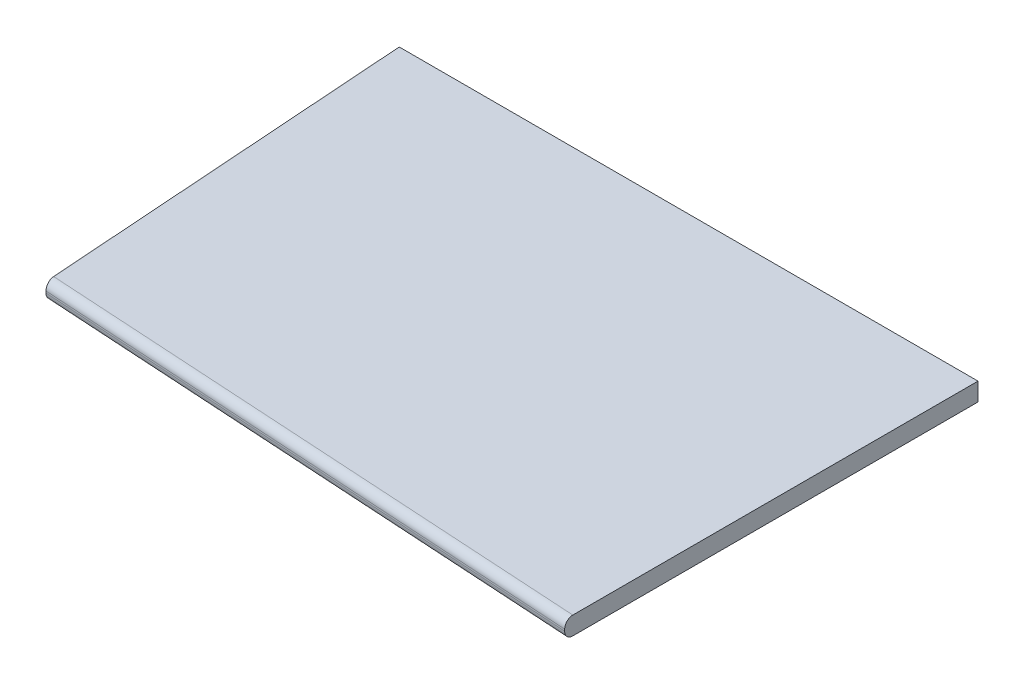
from build123d import *

# Parameters (mm, degrees)
BOSS_EXTRUDE1_DEPTH = 1.27
FILLET1_R           = 1.143


with BuildPart() as part:
    # Sketch1 → Boss-Extrude1 (new body, symmetric)
    with BuildSketch(Plane(origin=(0, 0, 0), x_dir=(1, 0, 0), z_dir=(0, 1, 0))):
        Polygon((0, 0), (81.28, 0), (81.28, -58.049008178), (3.729896149, -53.34), align=None)
    extrude(amount=BOSS_EXTRUDE1_DEPTH, both=True)

    # Fillet1
    fillet1_edges = [part.edges().sort_by_distance(p)[0] for p in [
        (42.504948075, -1.27, 55.694504089),
        (42.504948075, 1.27, 55.694504089),
    ]]
    fillet(fillet1_edges, radius=FILLET1_R)


solid = part.part
